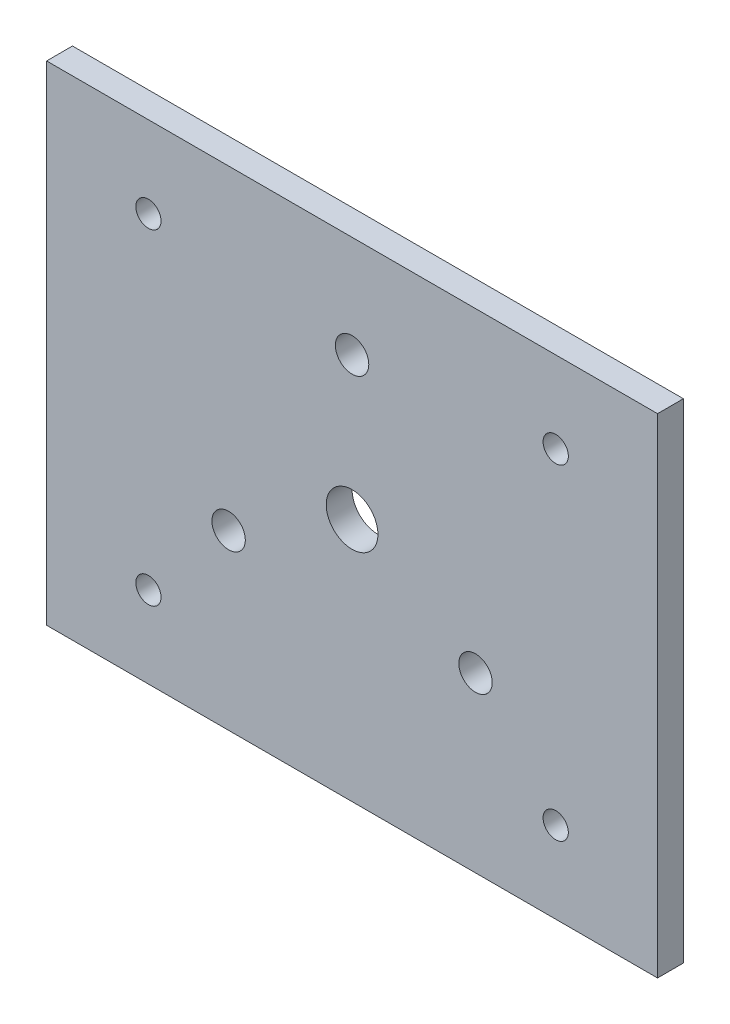
from build123d import *

# Parameters (mm, degrees)
CROQUIS1_W              = 150
CROQUIS1_H              = 120
CROQUIS1_R              = 4.1
CROQUIS1_R_2            = 3.1
CROQUIS1_R_3            = 6.35
SALIENTE_EXTRUIR1_DEPTH = 6.35


with BuildPart() as part:
    # Croquis1 → Saliente-Extruir1 (new body)
    with BuildSketch(Plane.XY):
        Rectangle(CROQUIS1_W, CROQUIS1_H)
        with Locations((0, 35)):
            Circle(CROQUIS1_R, mode=Mode.SUBTRACT)
        with Locations((-50, -40)):
            Circle(CROQUIS1_R_2, mode=Mode.SUBTRACT)
        with Locations((30.310889132, -17.5)):
            Circle(CROQUIS1_R, mode=Mode.SUBTRACT)
        with Locations((-30.310889132, -17.5)):
            Circle(CROQUIS1_R, mode=Mode.SUBTRACT)
        with Locations((50, -40)):
            Circle(CROQUIS1_R_2, mode=Mode.SUBTRACT)
        with Locations((50, 40)):
            Circle(CROQUIS1_R_2, mode=Mode.SUBTRACT)
        with Locations((-50, 40)):
            Circle(CROQUIS1_R_2, mode=Mode.SUBTRACT)
        Circle(CROQUIS1_R_3, mode=Mode.SUBTRACT)
    extrude(amount=SALIENTE_EXTRUIR1_DEPTH)


solid = part.part
